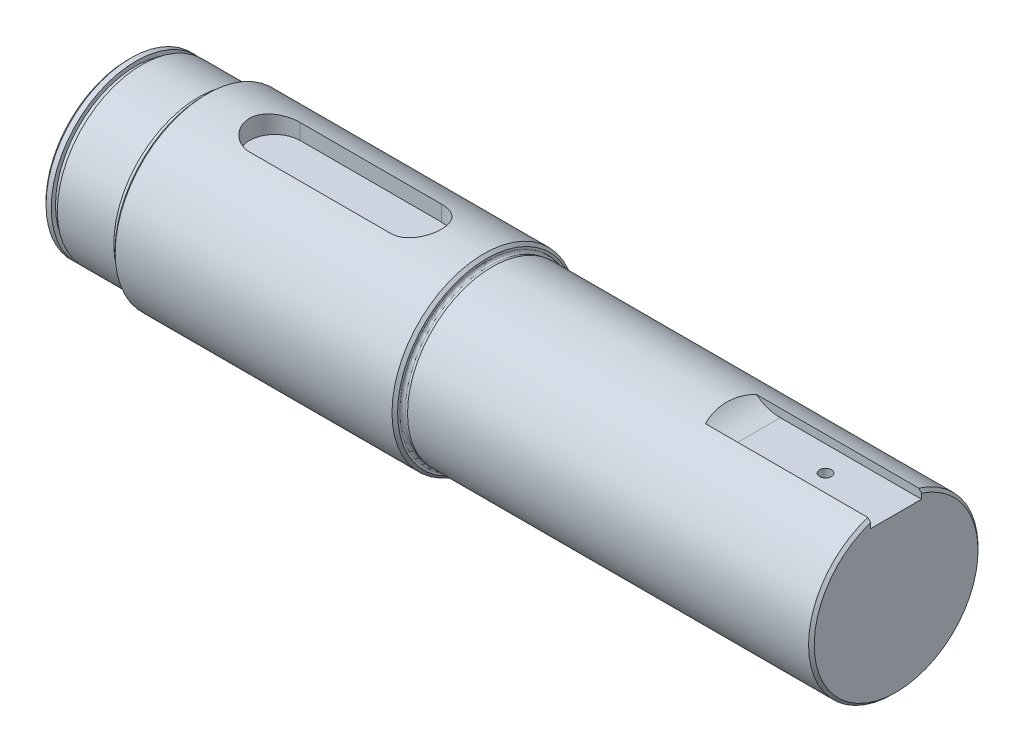
from build123d import *

# Parameters (mm, degrees)
CHAMFER1_SIZE                  = 1
CUT_EXTRUDE1_REACH             = 8.8
F_5_0MM_DOWEL_HOLE1_D          = 4.2
F_5_0MM_DOWEL_HOLE1_DEPTH      = 5
F_5_0MM_DOWEL_HOLE1_TIP        = 1.2618073
CUT_EXTRUDE2_REACH             = 34.5
CUT_EXTRUDE2_DIRECTION_2_REACH = 34.5


with BuildPart() as part:
    # Sketch1 → Revolve1 (revolve)
    with BuildSketch(Plane.XY):
        with BuildLine():
            Line((0, 0), (272, 0))
            Line((272, 0), (272, 30))
            Line((272, 30), (129, 30))
            Line((129, 30), (127.954891423, 29.719964001))
            ThreePointArc((127.954891423, 29.719964001), (127.182150762, 29.927019237), (126.975095526, 30.699759898))
            Line((126.975095526, 30.699759898), (127, 30.792704662))
            Line((127, 30.792704662), (127, 32.5))
            Line((127, 32.5), (27, 32.5))
            Line((27, 32.5), (27, 30.792704662))
            Line((27, 30.792704662), (27.024904474, 30.699759898))
            ThreePointArc((27.024904474, 30.699759898), (26.817849238, 29.927019237), (26.045108577, 29.719964001))
            Line((26.045108577, 29.719964001), (25, 30))
            Line((25, 30), (5, 30))
            Line((5, 30), (5, 28.5))
            Line((5, 28.5), (2.85, 28.5))
            Line((2.85, 28.5), (2.85, 30))
            Line((2.85, 30), (0, 30))
            Line((0, 30), (0, 0))
        make_face()
    revolve(axis=Axis((0, 0, 0), (1, 0, 0)))

    # Chamfer1
    chamfer1_edges = [part.edges().sort_by_distance(p)[0] for p in [
        (272, -30, 0),
        (127, -32.5, 0),
        (27, -32.5, 0),
        (0, -30, 0),
    ]]
    chamfer(chamfer1_edges, length=CHAMFER1_SIZE)

    # Sketch2 → Cut-Extrude1 (cut, up to next)
    with BuildSketch(Plane(origin=(0, 25.7, 0), x_dir=(1, 0, 0), z_dir=(0, 1, 0)), mode=Mode.PRIVATE) as cut_extrude1_sk1:
        Polygon((272, 9), (222, 9), (222, -9), (272, -9), (272, 0), align=None)
    cut_extrude1_tool1 = extrude(cut_extrude1_sk1.sketch, amount=CUT_EXTRUDE1_REACH, mode=Mode.PRIVATE) & part.part
    add(cut_extrude1_tool1.solids().sort_by_distance((247, 25.7, 0))[0], mode=Mode.SUBTRACT)
    # Sketch2 → Cut-Extrude1 (cut, up to next)
    with BuildSketch(Plane(origin=(0, 25.7, 0), x_dir=(1, 0, 0), z_dir=(0, 1, 0)), mode=Mode.PRIVATE) as cut_extrude1_sk2:
        with BuildLine():
            Line((52, 9), (102, 9))
            ThreePointArc((102, 9), (111, 0), (102, -9))
            Line((102, -9), (52, -9))
            ThreePointArc((52, -9), (43, 0), (52, 9))
        make_face()
    cut_extrude1_tool2 = extrude(cut_extrude1_sk2.sketch, amount=CUT_EXTRUDE1_REACH, mode=Mode.PRIVATE) & part.part
    add(cut_extrude1_tool2.solids().sort_by_distance((77, 25.7, 0))[0], mode=Mode.SUBTRACT)

    # Ø5.0mm Dowel Hole1
    with Locations(Plane(origin=(247, 25.7, 0), x_dir=(0, 0, 1), z_dir=(0, 1, 0))):
        with Locations((0, 0)):
            Hole(F_5_0MM_DOWEL_HOLE1_D / 2, depth=F_5_0MM_DOWEL_HOLE1_DEPTH)
            with Locations((0, 0, -(F_5_0MM_DOWEL_HOLE1_DEPTH + F_5_0MM_DOWEL_HOLE1_TIP / 2))):  # 118° drill point
                Cone(0, F_5_0MM_DOWEL_HOLE1_D / 2, F_5_0MM_DOWEL_HOLE1_TIP, mode=Mode.SUBTRACT)

    # Cut-Extrude2: up to this face of the body (flat: up to its plane)
    cut_extrude2_end = Plane(part.part.faces().sort_by_distance((246.910970255, 27.155084714, -9))[0])
    # Sketch5 → Cut-Extrude2 (cut, up to the picked face)
    with BuildSketch(Plane.XY, mode=Mode.PRIVATE) as cut_extrude2_sk1:
        with BuildLine():
            Line((222, 30), (222, 25.7))
            ThreePointArc((222, 25.7), (216.557344398, 26.820568368), (212, 30))
            Line((212, 30), (222, 30))
        make_face()
    cut_extrude2_tool1 = split(extrude(cut_extrude2_sk1.sketch, amount=-CUT_EXTRUDE2_REACH, mode=Mode.PRIVATE), bisect_by=cut_extrude2_end, keep=Keep.BOTH, mode=Mode.PRIVATE)
    add(cut_extrude2_tool1.solids().sort_by_distance((218.157433, 28.254696, 0))[0], mode=Mode.SUBTRACT)

    # Cut-Extrude2 direction 2: up to this face of the body (flat: up to its plane)
    cut_extrude2_direction_2_end = Plane(part.part.faces().sort_by_distance((246.910970255, 27.155084714, 9))[0])
    # Sketch5 → Cut-Extrude2 direction 2 (cut, up to the picked face)
    with BuildSketch(Plane.XY, mode=Mode.PRIVATE) as cut_extrude2_direction_2_sk1:
        with BuildLine():
            Line((222, 30), (222, 25.7))
            ThreePointArc((222, 25.7), (216.557344398, 26.820568368), (212, 30))
            Line((212, 30), (222, 30))
        make_face()
    cut_extrude2_direction_2_tool1 = split(extrude(cut_extrude2_direction_2_sk1.sketch, amount=CUT_EXTRUDE2_DIRECTION_2_REACH, mode=Mode.PRIVATE), bisect_by=cut_extrude2_direction_2_end, keep=Keep.BOTH, mode=Mode.PRIVATE)
    add(cut_extrude2_direction_2_tool1.solids().sort_by_distance((218.157433, 28.254696, 0))[0], mode=Mode.SUBTRACT)


solid = part.part
